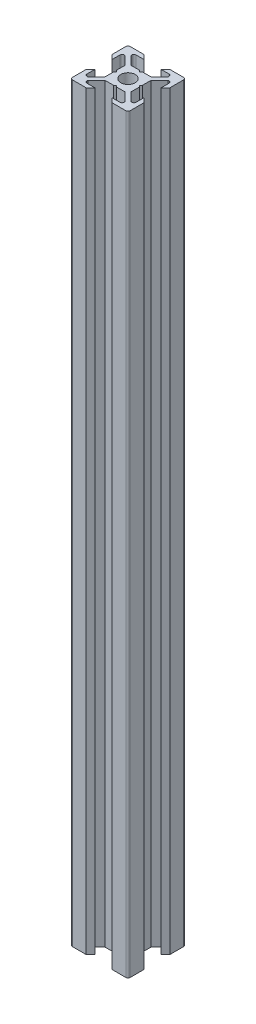
from build123d import *

# Parameters (mm, degrees)
ESQUISSE1_R      = 2.5
EXTRUSION1_DEPTH = 260
CONG_1_R         = 0.75


with BuildPart() as part:
    # Esquisse1 → Extrusion1 (new body)
    with BuildSketch(Plane(origin=(0, 0, 0), x_dir=(1, 0, 0), z_dir=(0, 1, 0))):
        Polygon((0, 4), (-0.5, 4.5), (-3.439339828, 4.5), (-6.439339828, 7.5), (-6.439339828, 8.5), (-3, 8.5), (-4.5, 10), (-10, 10), (-10, 4.5), (-8.5, 3), (-8.5, 6.439339828), (-7.5, 6.439339828), (-4.5, 3.439339828), (-4.5, 0.5), (-4, 0), (-4.5, -0.5), (-4.5, -3.439339828), (-7.5, -6.439339828), (-8.5, -6.439339828), (-8.5, -3), (-10, -4.5), (-10, -10), (-4.5, -10), (-3, -8.5), (-6.439339828, -8.5), (-6.439339828, -7.5), (-3.439339828, -4.5), (-0.5, -4.5), (0, -4), (0.5, -4.5), (3.439339828, -4.5), (6.439339828, -7.5), (6.439339828, -8.5), (3, -8.5), (4.5, -10), (10, -10), (10, -4.5), (8.5, -3), (8.5, -6.439339828), (7.5, -6.439339828), (4.5, -3.439339828), (4.5, -0.5), (4, 0), (4.5, 0.5), (4.5, 3.439339828), (7.5, 6.439339828), (8.5, 6.439339828), (8.5, 3), (10, 4.5), (10, 10), (4.5, 10), (3, 8.5), (6.439339828, 8.5), (6.439339828, 7.5), (3.439339828, 4.5), (0.5, 4.5), align=None)
        Circle(ESQUISSE1_R, mode=Mode.SUBTRACT)
    extrude(amount=EXTRUSION1_DEPTH)

    # Congé1
    cong_1_edges = [part.edges().sort_by_distance(p)[0] for p in [
        (6.439339828, 130, -8.5),
        (10, 130, -10),
        (8.5, 130, -6.439339828),
        (8.5, 130, 6.439339828),
        (10, 130, 10),
        (6.439339828, 130, 8.5),
        (-6.439339828, 130, 8.5),
        (-10, 130, 10),
        (-8.5, 130, 6.439339828),
        (-8.5, 130, -6.439339828),
        (-10, 130, -10),
        (-6.439339828, 130, -8.5),
    ]]
    fillet(cong_1_edges, radius=CONG_1_R)


solid = part.part
